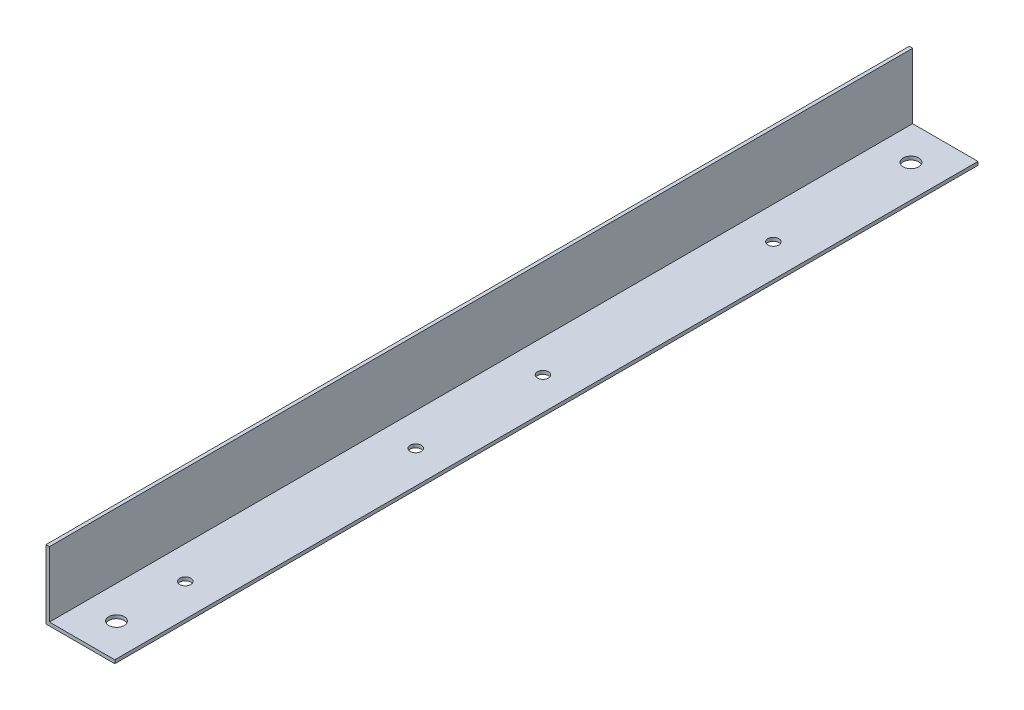
from build123d import *

# Parameters (mm, degrees)
EXTRUDE_1_DEPTH     = 251
SKETCH_2_R          = 1.6
CUT_EXTRUDE_1_DEPTH = 2
SKETCH_3_R          = 2.25
CUT_EXTRUDE_2_DEPTH = 2


with BuildPart() as part:
    # Эскиз1 → Бобышка-Вытянуть1 (new body)
    with BuildSketch(Plane.XY):
        Polygon((0, 0), (0, 20), (1, 20), (1, 1), (20, 1), (20, 0), align=None)
    extrude(amount=EXTRUDE_1_DEPTH)

    # Эскиз2 → Вырез-Вытянуть1 (cut, through all)
    with BuildSketch(Plane(origin=(0, 1, 0), x_dir=(1, 0, 0), z_dir=(0, 1, 0))):
        with Locations((10.5, -50)):
            Circle(SKETCH_2_R)
        with Locations((10.5, -117)):
            Circle(SKETCH_2_R)
        with Locations((10.5, -221)):
            Circle(SKETCH_2_R)
        with Locations((10.5, -154)):
            Circle(SKETCH_2_R)
    extrude(amount=-CUT_EXTRUDE_1_DEPTH, mode=Mode.SUBTRACT)

    # Эскиз3 → Вырез-Вытянуть2 (cut, through all)
    with BuildSketch(Plane(origin=(0, 1, 0), x_dir=(1, 0, 0), z_dir=(0, 1, 0))):
        with Locations((10.5, -241)):
            Circle(SKETCH_3_R)
        with Locations((10.5, -10)):
            Circle(SKETCH_3_R)
    extrude(amount=-CUT_EXTRUDE_2_DEPTH, mode=Mode.SUBTRACT)


solid = part.part
